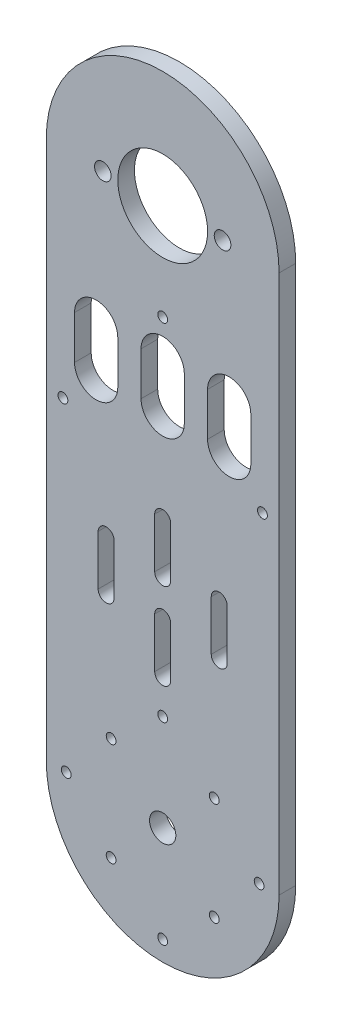
from build123d import *

# Parameters (mm, degrees)
SKETCH1_R           = 3.95
SKETCH1_R_2         = 1.475
SKETCH1_R_3         = 13.5
SKETCH1_R_4         = 2.5
BOSS_EXTRUDE1_DEPTH = 5


with BuildPart() as part:
    # Sketch1 → Boss-Extrude1 (new body)
    with BuildSketch(Plane.XY):
        with BuildLine():
            Line((35, 0), (35, 162))
            ThreePointArc((35, 162), (0, 197), (-35, 162))
            Line((-35, 162), (-35, 0))
            ThreePointArc((-35, 0), (0, -35), (35, 0))
        make_face()
        Circle(SKETCH1_R, mode=Mode.SUBTRACT)
        with Locations((15.5, 15.5)):
            Circle(SKETCH1_R_2, mode=Mode.SUBTRACT)
        with Locations((15.5, -15.5)):
            Circle(SKETCH1_R_2, mode=Mode.SUBTRACT)
        with Locations((-15.5, -15.5)):
            Circle(SKETCH1_R_2, mode=Mode.SUBTRACT)
        with Locations((-15.5, 15.5)):
            Circle(SKETCH1_R_2, mode=Mode.SUBTRACT)
        with Locations((0, 29)):
            Circle(SKETCH1_R_2, mode=Mode.SUBTRACT)
        with Locations((0, 162)):
            Circle(SKETCH1_R_3, mode=Mode.SUBTRACT)
        with Locations((-18, 162)):
            Circle(SKETCH1_R_4, mode=Mode.SUBTRACT)
        with Locations((18, 162)):
            Circle(SKETCH1_R_4, mode=Mode.SUBTRACT)
        with Locations((0, 133)):
            Circle(SKETCH1_R_2, mode=Mode.SUBTRACT)
        with Locations((-30, 97)):
            Circle(SKETCH1_R_2, mode=Mode.SUBTRACT)
        with Locations((30, 97)):
            Circle(SKETCH1_R_2, mode=Mode.SUBTRACT)
        with Locations((29, 0)):
            Circle(SKETCH1_R_2, mode=Mode.SUBTRACT)
        with Locations((0, -29)):
            Circle(SKETCH1_R_2, mode=Mode.SUBTRACT)
        with Locations((-29, 0)):
            Circle(SKETCH1_R_2, mode=Mode.SUBTRACT)
        with BuildLine():
            Line((2.4, 54.5), (2.4, 39.5))
            ThreePointArc((2.4, 39.5), (0, 37.1), (-2.4, 39.5))
            Line((-2.4, 39.5), (-2.4, 54.5))
            ThreePointArc((-2.4, 54.5), (0, 56.9), (2.4, 54.5))
        make_face(mode=Mode.SUBTRACT)
        with BuildLine():
            Line((2.4, 80.5), (2.4, 65.5))
            ThreePointArc((2.4, 65.5), (0, 63.1), (-2.4, 65.5))
            Line((-2.4, 65.5), (-2.4, 80.5))
            ThreePointArc((-2.4, 80.5), (0, 82.9), (2.4, 80.5))
        make_face(mode=Mode.SUBTRACT)
        with BuildLine():
            Line((19.4, 67.5), (19.4, 52.5))
            ThreePointArc((19.4, 52.5), (17, 50.1), (14.6, 52.5))
            Line((14.6, 52.5), (14.6, 67.5))
            ThreePointArc((14.6, 67.5), (17, 69.9), (19.4, 67.5))
        make_face(mode=Mode.SUBTRACT)
        with BuildLine():
            Line((-19.4, 67.5), (-19.4, 52.5))
            ThreePointArc((-19.4, 52.5), (-17, 50.1), (-14.6, 52.5))
            Line((-14.6, 52.5), (-14.6, 67.5))
            ThreePointArc((-14.6, 67.5), (-17, 69.9), (-19.4, 67.5))
        make_face(mode=Mode.SUBTRACT)
        with BuildLine():
            Line((6.5, 121.5), (6.5, 108.5))
            ThreePointArc((6.5, 108.5), (0, 102), (-6.5, 108.5))
            Line((-6.5, 108.5), (-6.5, 121.5))
            ThreePointArc((-6.5, 121.5), (0, 128), (6.5, 121.5))
        make_face(mode=Mode.SUBTRACT)
        with BuildLine():
            Line((26.5, 120.946496324), (26.5, 107.946496324))
            ThreePointArc((26.5, 107.946496324), (20, 101.446496324), (13.5, 107.946496324))
            Line((13.5, 107.946496324), (13.5, 120.946496324))
            ThreePointArc((13.5, 120.946496324), (20, 127.446496324), (26.5, 120.946496324))
        make_face(mode=Mode.SUBTRACT)
        with BuildLine():
            Line((-26.5, 120.946496324), (-26.5, 107.946496324))
            ThreePointArc((-26.5, 107.946496324), (-20, 101.446496324), (-13.5, 107.946496324))
            Line((-13.5, 107.946496324), (-13.5, 120.946496324))
            ThreePointArc((-13.5, 120.946496324), (-20, 127.446496324), (-26.5, 120.946496324))
        make_face(mode=Mode.SUBTRACT)
    extrude(amount=BOSS_EXTRUDE1_DEPTH)


solid = part.part
